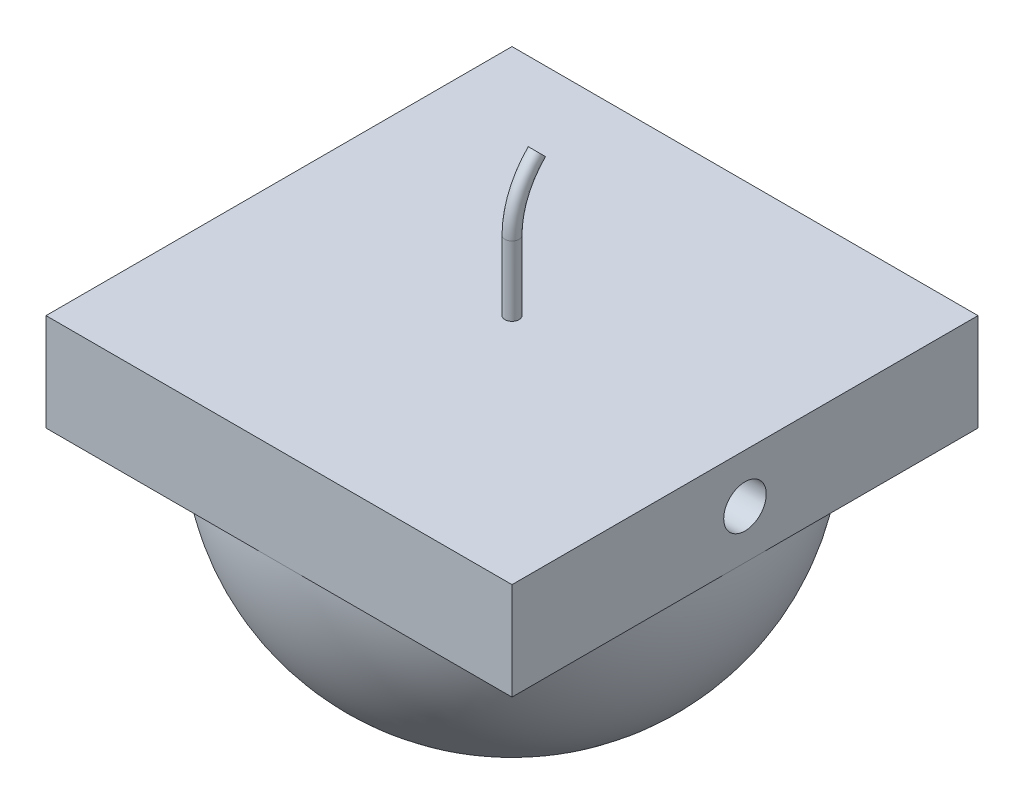
from build123d import *

# Parameters (mm, degrees)
SKETCH1_W               = 330.2
SKETCH1_H               = 330.2
BOSS_EXTRUDE1_DEPTH     = 69.02
SKETCH3_R               = 15.081646842
CUT_EXTRUDE1_DEPTH      = 166.1
CUT_EXTRUDE1_DEPTH_BACK = 166.1
REVOLVE3_ANGLE          = 180
SWEEP1_PROFILE_R        = 5


with BuildPart() as part:
    # Sketch1 → Boss-Extrude1 (new body)
    with BuildSketch(Plane(origin=(0, 0, 0), x_dir=(1, 0, 0), z_dir=(0, 1, 0))):
        Rectangle(SKETCH1_W, SKETCH1_H)
    extrude(amount=BOSS_EXTRUDE1_DEPTH)

    # Sketch3 → Cut-Extrude1 (cut, two sides)
    with BuildSketch(Plane.ZY) as cut_extrude1_sk:
        with Locations((0, 34.51)):
            Circle(SKETCH3_R)
    extrude(amount=CUT_EXTRUDE1_DEPTH, mode=Mode.SUBTRACT)
    extrude(cut_extrude1_sk.sketch, amount=-CUT_EXTRUDE1_DEPTH_BACK, mode=Mode.SUBTRACT)

    # Sketch4 → Revolve3 (revolve)
    with BuildSketch(Plane(origin=(0, 0, 0), x_dir=(1, 0, 0), z_dir=(0, 1, 0))):
        with BuildLine():
            Line((-116.743329574, 116.743329574), (116.743329574, -116.743329574))
            ThreePointArc((116.743329574, -116.743329574), (-116.743329574, -116.743329574), (-116.743329574, 116.743329574))
        make_face()
    revolve(axis=Axis((165.1, 0, 165.1), (0.707106781, 0, 0.707106781)), revolution_arc=REVOLVE3_ANGLE)

    # Sweep1: sweep along a path in Sketch5
    with BuildLine(Plane(origin=(0, 0, 0), x_dir=(0, 0, -1), z_dir=(1, 0, 0))) as sweep1_path:
        Line((0, 69.02), (0, 118.307775501))
        ThreePointArc((0, 118.307775501), (4.579113421, 141.32853324), (17.619325174, 160.844589296))
    # Sweep1 profile (on start of the path) → Sweep1 (sweep)
    with BuildSketch(Plane.ZX.offset(69.02)):
        Circle(SWEEP1_PROFILE_R)
    sweep(path=sweep1_path.line)


solid = part.part
